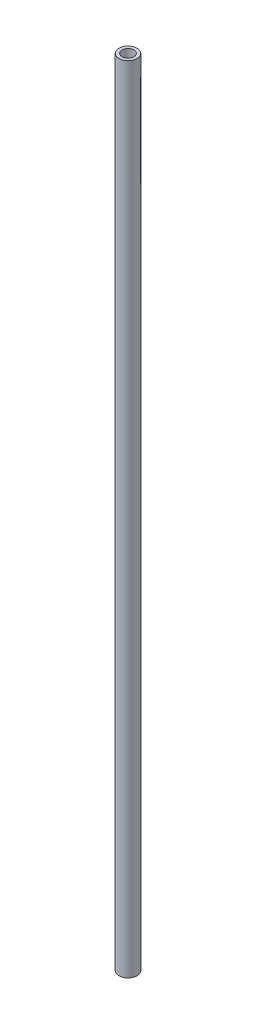
from build123d import *

# Parameters (mm, degrees)
SKETCH1_R           = 2.9
SKETCH1_R_2         = 1.9
BOSS_EXTRUDE1_DEPTH = 255.3116


with BuildPart() as part:
    # Sketch1 → Boss-Extrude1 (new body)
    with BuildSketch(Plane(origin=(0, 0, 0), x_dir=(1, 0, 0), z_dir=(0, 1, 0))):
        Circle(SKETCH1_R)
        Circle(SKETCH1_R_2, mode=Mode.SUBTRACT)
    extrude(amount=BOSS_EXTRUDE1_DEPTH)


solid = part.part
